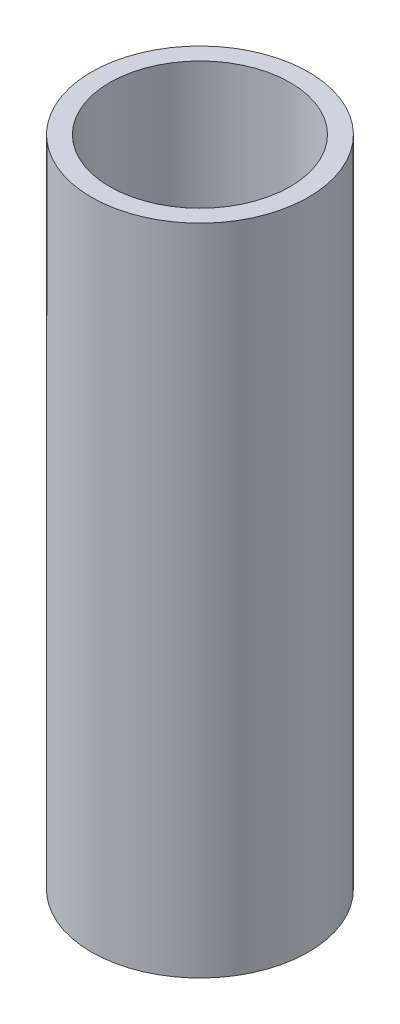
from build123d import *

# Parameters (mm, degrees)
SKETCH1_R           = 21.082
SKETCH1_R_2         = 17.526
BOSS_EXTRUDE1_DEPTH = 127


with BuildPart() as part:
    # Sketch1 → Boss-Extrude1 (new body)
    with BuildSketch(Plane(origin=(0, 0, 0), x_dir=(1, 0, 0), z_dir=(0, 1, 0))):
        Circle(SKETCH1_R)
        Circle(SKETCH1_R_2, mode=Mode.SUBTRACT)
    extrude(amount=BOSS_EXTRUDE1_DEPTH)


solid = part.part
